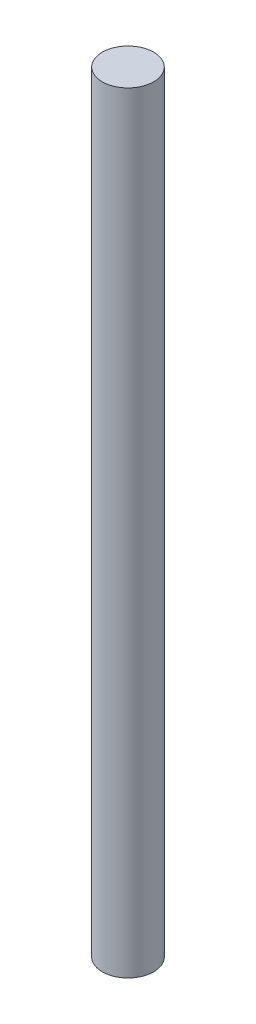
from build123d import *

# Parameters (mm, degrees)
CROQUIS1_R              = 2.5
SALIENTE_EXTRUIR1_DEPTH = 75


with BuildPart() as part:
    # Croquis1 → Saliente-Extruir1 (new body)
    with BuildSketch(Plane(origin=(0, 0, 0), x_dir=(1, 0, 0), z_dir=(0, 1, 0))):
        Circle(CROQUIS1_R)
    extrude(amount=SALIENTE_EXTRUIR1_DEPTH)


solid = part.part
